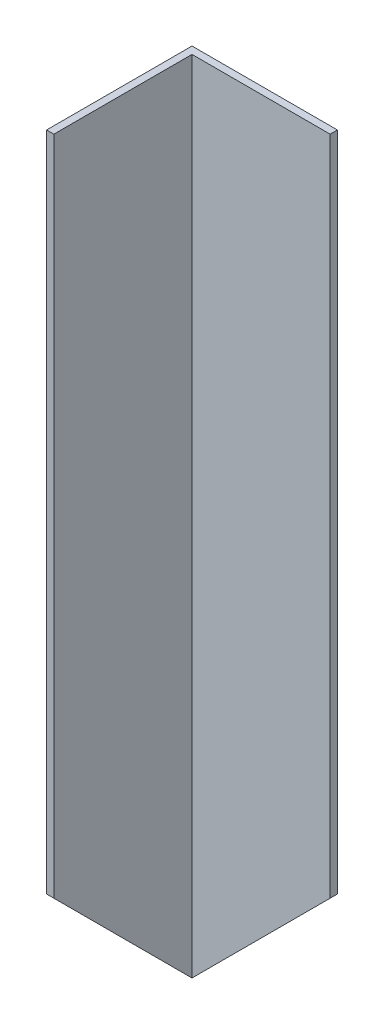
from build123d import *

# Parameters (mm, degrees)
BOSS_EXTRU_1_DEPTH      = 222
ENL_V_MAT_EXTRU_1_DEPTH = 590
ENL_V_MAT_EXTRU_2_DEPTH = 590


with BuildPart() as part:
    # Esquisse1 → Boss.-Extru.1 (new body)
    with BuildSketch(Plane(origin=(0, 0, 0), x_dir=(1, 0, 0), z_dir=(0, 1, 0))):
        Polygon((-20, 20.113636364), (20, 20.113636364), (20, 18.113636364), (-18, 18.113636364), (-18, -19.886363636), (-20, -19.886363636), align=None)
    extrude(amount=BOSS_EXTRU_1_DEPTH)

    # Esquisse2 → Enlèv. mat.-Extru.1 (cut)
    with BuildSketch(Plane(origin=(0, 0, -20.113636364), x_dir=(-1, 0, 0), z_dir=(0, 0, -1))):
        Polygon((20, 0), (-20, 40), (-20, 0), align=None)
    extrude(amount=-ENL_V_MAT_EXTRU_1_DEPTH, mode=Mode.SUBTRACT)

    # Esquisse3 → Enlèv. mat.-Extru.2 (cut)
    with BuildSketch(Plane.ZY.offset(20)):
        Polygon((-20.113636364, 0), (19.886363636, 40), (19.886363636, 0), align=None)
    extrude(amount=-ENL_V_MAT_EXTRU_2_DEPTH, mode=Mode.SUBTRACT)


solid = part.part
